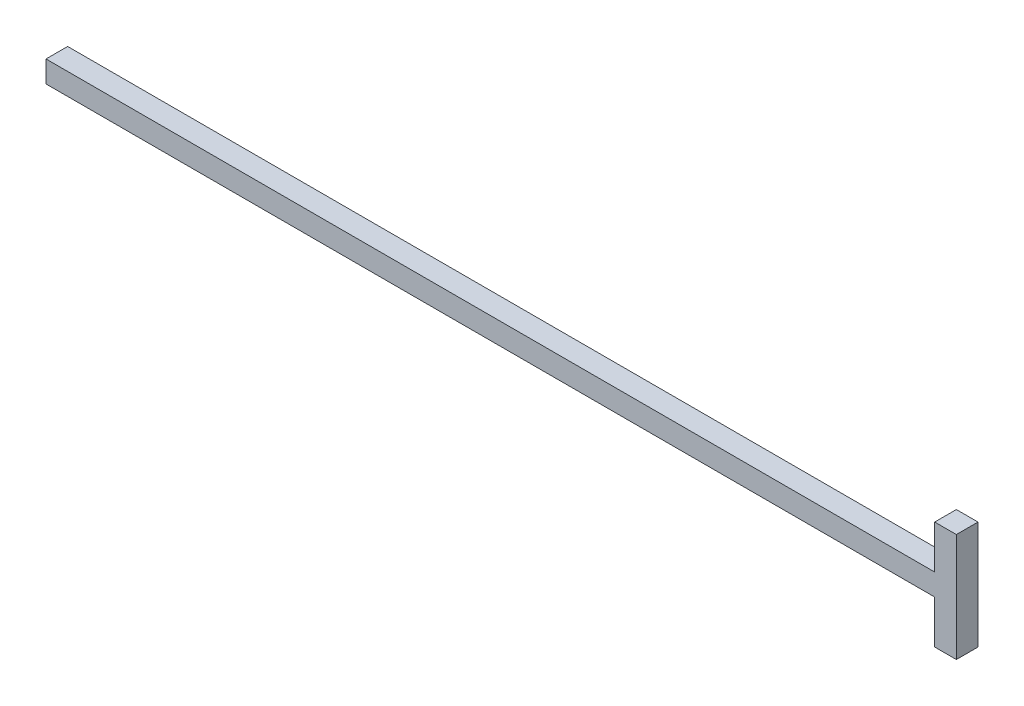
from build123d import *

# Parameters (mm, degrees)
SKETCH1_W           = 266.954
SKETCH1_H           = 6.35
SKETCH1_W_2         = 6.35
SKETCH1_H_2         = 12.7
BOSS_EXTRUDE1_DEPTH = 6.35


with BuildPart() as part:
    # Sketch1 → Boss-Extrude1 (new body)
    with BuildSketch(Plane.XY):
        Rectangle(SKETCH1_W, SKETCH1_H)
        with Locations((130.302, 9.525)):
            Rectangle(SKETCH1_W_2, SKETCH1_H_2)
        with Locations((130.302, -9.525)):
            Rectangle(SKETCH1_W_2, SKETCH1_H_2)
    extrude(amount=BOSS_EXTRUDE1_DEPTH)


solid = part.part
